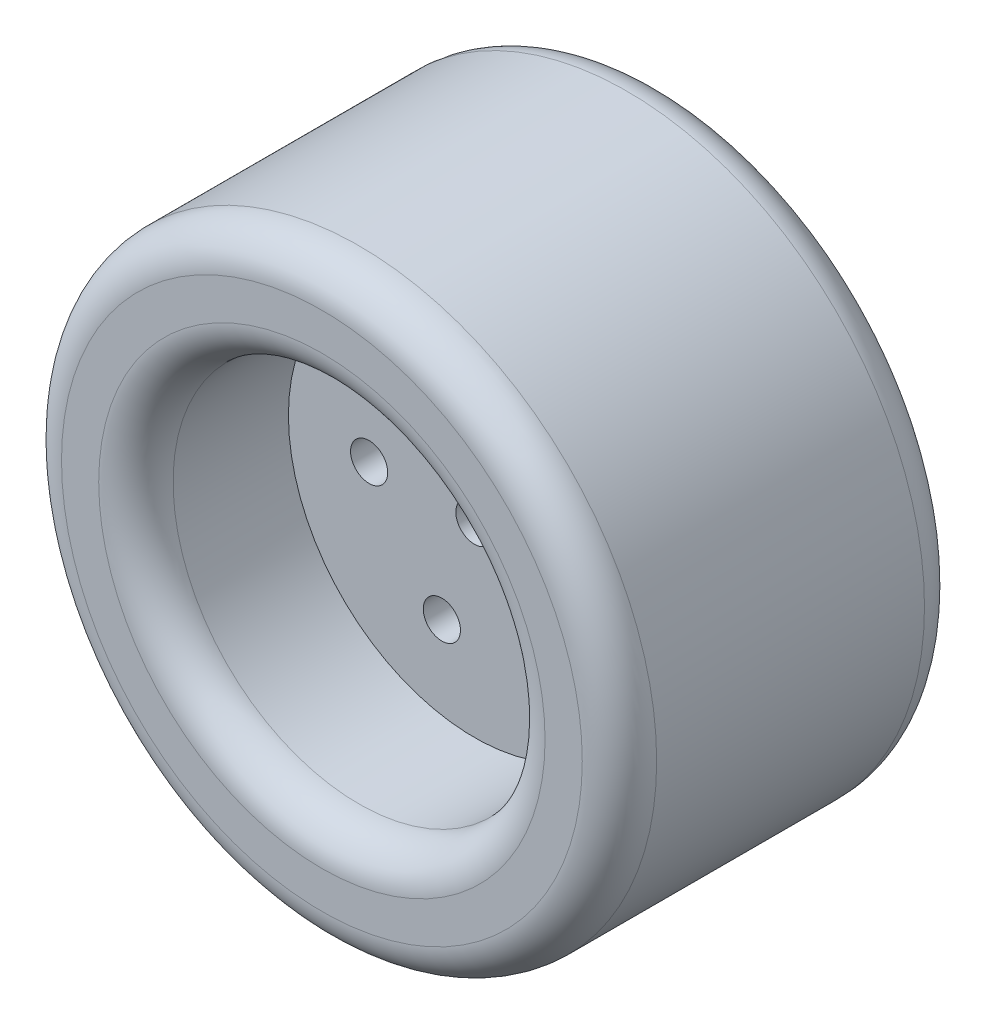
from build123d import *

# Parameters (mm, degrees)
SKETCH2_R                = 101.6
SKETCH2_R_2              = 63.5
BOSS_EXTRUDE1_DEPTH      = 114.3
BOSS_EXTRUDE1_DEPTH_BACK = 2.54
FILLET1_R                = 12.7
SKETCH4_R                = 63.5
BOSS_EXTRUDE2_DEPTH      = 6.35
BOSS_EXTRUDE2_DEPTH_BACK = 6.35
SKETCH13_R               = 6.35
CUT_EXTRUDE1_DEPTH       = 50.53
CUT_EXTRUDE1_DEPTH_BACK  = 68.3100001


with BuildPart() as part:
    # Sketch2 → Boss-Extrude1 (new body, two sides)
    with BuildSketch(Plane.XY) as boss_extrude1_sk:
        Circle(SKETCH2_R)
        Circle(SKETCH2_R_2, mode=Mode.SUBTRACT)
    extrude(amount=BOSS_EXTRUDE1_DEPTH)
    extrude(boss_extrude1_sk.sketch, amount=-BOSS_EXTRUDE1_DEPTH_BACK)

    # Fillet1
    fillet1_edges = [part.edges().sort_by_distance(p)[0] for p in [
        (-101.6, 0, -2.54),
        (-63.5, 0, -2.54),
        (-101.6, 0, 114.3),
        (-63.5, 0, 114.3),
    ]]
    fillet(fillet1_edges, radius=FILLET1_R)

    # Sketch4 → Boss-Extrude2 (add, two sides)
    with BuildSketch(Plane(origin=(0, 0, 55.88), x_dir=(-1, 0, 0), z_dir=(0, 0, -1))) as boss_extrude2_sk:
        Circle(SKETCH4_R)
    extrude(amount=BOSS_EXTRUDE2_DEPTH)
    extrude(boss_extrude2_sk.sketch, amount=-BOSS_EXTRUDE2_DEPTH_BACK)

    # Sketch13 → Cut-Extrude1 (cut, two sides)
    with BuildSketch(Plane.XY.offset(64.77)) as cut_extrude1_sk:
        Circle(SKETCH13_R)
        with Locations((-35.941, 0)):
            Circle(SKETCH13_R)
        with Locations((-11.106379795, 34.181922252)):
            Circle(SKETCH13_R)
        with Locations((29.076879795, 21.125589753)):
            Circle(SKETCH13_R)
        with Locations((29.076879795, -21.125589753)):
            Circle(SKETCH13_R)
        with Locations((-11.106379795, -34.181922252)):
            Circle(SKETCH13_R)
    extrude(amount=CUT_EXTRUDE1_DEPTH, mode=Mode.SUBTRACT)
    extrude(cut_extrude1_sk.sketch, amount=-CUT_EXTRUDE1_DEPTH_BACK, mode=Mode.SUBTRACT)


solid = part.part
